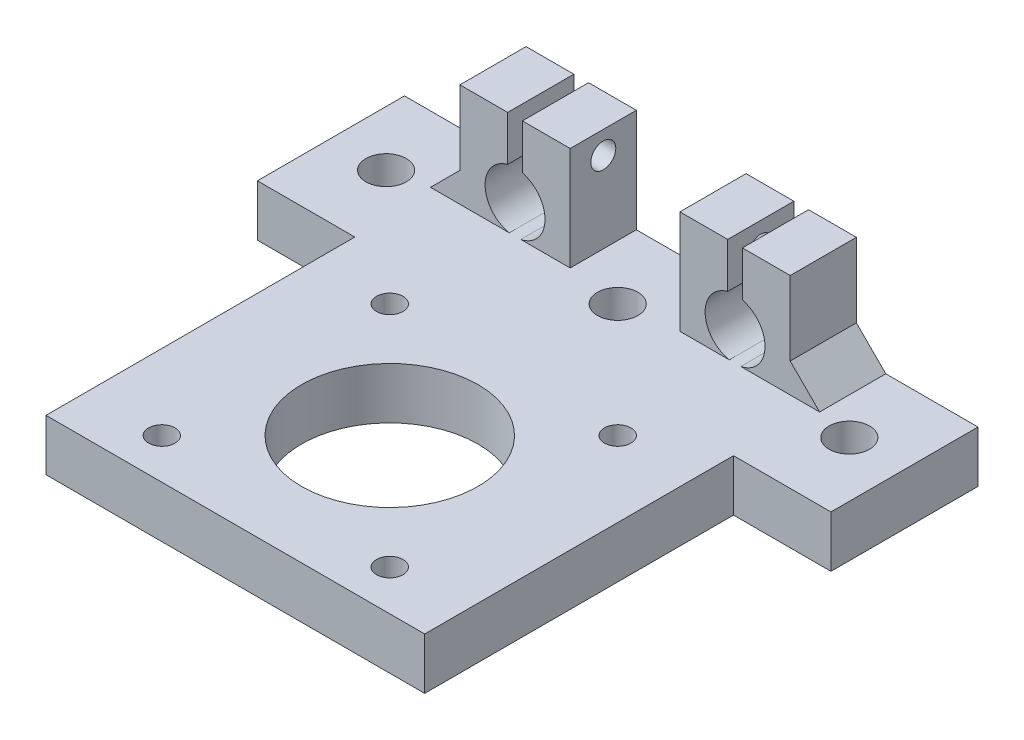
from build123d import *

# Parameters (mm, degrees)
SKETCH1_W            = 42
SKETCH1_H            = 42
BOSS_EXTRUDE1_DEPTH  = 3
M3_CLEARANCE_HOLE1_D = 3.6
SKETCH4_R            = 12
CUT_EXTRUDE1_DEPTH   = 30.849623113
BOSS_EXTRUDE2_START  = -34
SKETCH5_R            = 4
BOSS_EXTRUDE2_DEPTH  = 20
SKETCH6_W            = 42
SKETCH6_H            = 20
BOSS_EXTRUDE3_DEPTH  = 3
SKETCH7_W            = 4.75
SKETCH7_H            = 62
BOSS_EXTRUDE4_DEPTH  = 3
BOSS_EXTRUDE5_START  = -7
BOSS_EXTRUDE5_DEPTH  = 9
SKETCH13_W           = 13.25
SKETCH13_H           = 20
BOSS_EXTRUDE6_DEPTH  = 3
M5_CLEARANCE_HOLE1_D = 5.5
CHAMFER1_SIZE        = 4
MOVE_FACE1_BY        = 4


with BuildPart() as part:
    # Sketch1 → Boss-Extrude1 (new body)
    with BuildSketch(Plane(origin=(0, 0, 0), x_dir=(1, 0, 0), z_dir=(0, 1, 0))):
        Rectangle(SKETCH1_W, SKETCH1_H)
    extrude(amount=BOSS_EXTRUDE1_DEPTH)

    # M3 Clearance Hole1 (through all)
    with Locations(Plane(origin=(0, 3, 0), x_dir=(1, 0, 0), z_dir=(0, 1, 0))):
        with Locations((-15.5, 15.5), (-15.5, -15.5), (15.5, -15.5), (15.5, 15.5)):
            Hole(M3_CLEARANCE_HOLE1_D / 2)

    # Sketch4 → Cut-Extrude1 (cut, through all)
    with BuildSketch(Plane(origin=(0, 3, 0), x_dir=(1, 0, 0), z_dir=(0, 1, 0))):
        with Locations(Location((0, 0, 0), (0, 0, 270))):
            Circle(SKETCH4_R)
    extrude(amount=-CUT_EXTRUDE1_DEPTH, mode=Mode.SUBTRACT)

    # Sketch6 → Boss-Extrude3 (add)
    with BuildSketch(Plane(origin=(0, 0, 0), x_dir=(1, 0, 0), z_dir=(0, 1, 0))):
        with Locations((0, 31)):
            Rectangle(SKETCH6_W, SKETCH6_H)
    extrude(amount=BOSS_EXTRUDE3_DEPTH)

    # Sketch7 → Boss-Extrude4 (add)
    with BuildSketch(Plane(origin=(0, 0, 0), x_dir=(1, 0, 0), z_dir=(0, 1, 0))):
        with Locations((-23.375, 10)):
            Rectangle(SKETCH7_W, SKETCH7_H)
        with Locations((23.375, 10)):
            Rectangle(SKETCH7_W, SKETCH7_H)
    extrude(amount=BOSS_EXTRUDE4_DEPTH)

    # Sketch8 → Boss-Extrude5 (add)
    with BuildSketch(Plane.XY.offset(-34).offset(BOSS_EXTRUDE5_START)):
        with BuildLine():
            Line((-22.46, 17.075), (-22.46, 3))
            Line((-22.46, 3), (-15.738219121, 3))
            ThreePointArc((-15.738219121, 3), (-19.033415417, 6.886369723), (-15.96, 10.95039555))
            Line((-15.96, 10.95039555), (-15.96, 17.075))
            Line((-15.96, 17.075), (-22.46, 17.075))
        make_face()
        with BuildLine():
            ThreePointArc((-13.96, 10.95039555), (-10.886584583, 6.886369723), (-14.181780879, 3))
            Line((-14.181780879, 3), (-7.46, 3))
            Line((-7.46, 3), (-7.46, 17.075))
            Line((-7.46, 17.075), (-13.96, 17.075))
            Line((-13.96, 17.075), (-13.96, 10.95039555))
        make_face()
    boss_extrude5 = extrude(amount=BOSS_EXTRUDE5_DEPTH)

    # Sketch10 → M3 Clearance Hole2 (revolve, cut)
    with BuildSketch(Plane(origin=(-7.46, 14.012697775, -36.5), x_dir=(0, 0, -1), z_dir=(0, 1, 0))):
        Polygon((0, 0), (0, 7.371463052), (1.7, 6.35), (1.7, 0), align=None)
    m3_clearance_hole2 = revolve(axis=Axis((-1.11, 14.012697775, -36.5), (-1, 0, 0)), mode=Mode.SUBTRACT)

    # Mirror2: Boss-Extrude5, M3 Clearance Hole2 across plane
    add(boss_extrude5.mirror(Plane(origin=(0, 0, 0), x_dir=(0, 0, 1), z_dir=(1, 0, 0))))
    add(m3_clearance_hole2.mirror(Plane(origin=(0, 0, 0), x_dir=(0, 0, 1), z_dir=(1, 0, 0))), mode=Mode.SUBTRACT)

    # Sketch13 → Boss-Extrude6 (add)
    with BuildSketch(Plane(origin=(0, 3, 0), x_dir=(1, 0, 0), z_dir=(0, 1, 0))):
        with Locations((-32.375, 31)):
            Rectangle(SKETCH13_W, SKETCH13_H)
        with Locations((32.375, 31)):
            Rectangle(SKETCH13_W, SKETCH13_H)
    extrude(amount=-BOSS_EXTRUDE6_DEPTH)

    # M5 Clearance Hole1 (through all)
    with Locations(Plane(origin=(0, 3, 0), x_dir=(1, 0, 0), z_dir=(0, 1, 0))):
        with Locations((0, 31), (-31.5, 31), (31.5, 31)):
            Hole(M5_CLEARANCE_HOLE1_D / 2)

    # Chamfer1
    chamfer1_edges = [part.edges().sort_by_distance(p)[0] for p in [
        (22.46, 3, -36.5),
        (-22.46, 3, -36.5),
    ]]
    chamfer(chamfer1_edges, length=CHAMFER1_SIZE)

    # Move Face1: a face moved outward by 4.0
    extrude(part.faces().sort_by_distance((0, 0, -14.610959183))[0], amount=MOVE_FACE1_BY, dir=(0, -1, 0))


with BuildPart() as body_2:
    # Sketch5 → Boss-Extrude2 (new body)
    with BuildSketch(Plane.XY.offset(BOSS_EXTRUDE2_START)):
        with Locations((-14.96, 7)):
            Circle(SKETCH5_R)
    extrude(amount=-BOSS_EXTRUDE2_DEPTH)


solid = part.part
